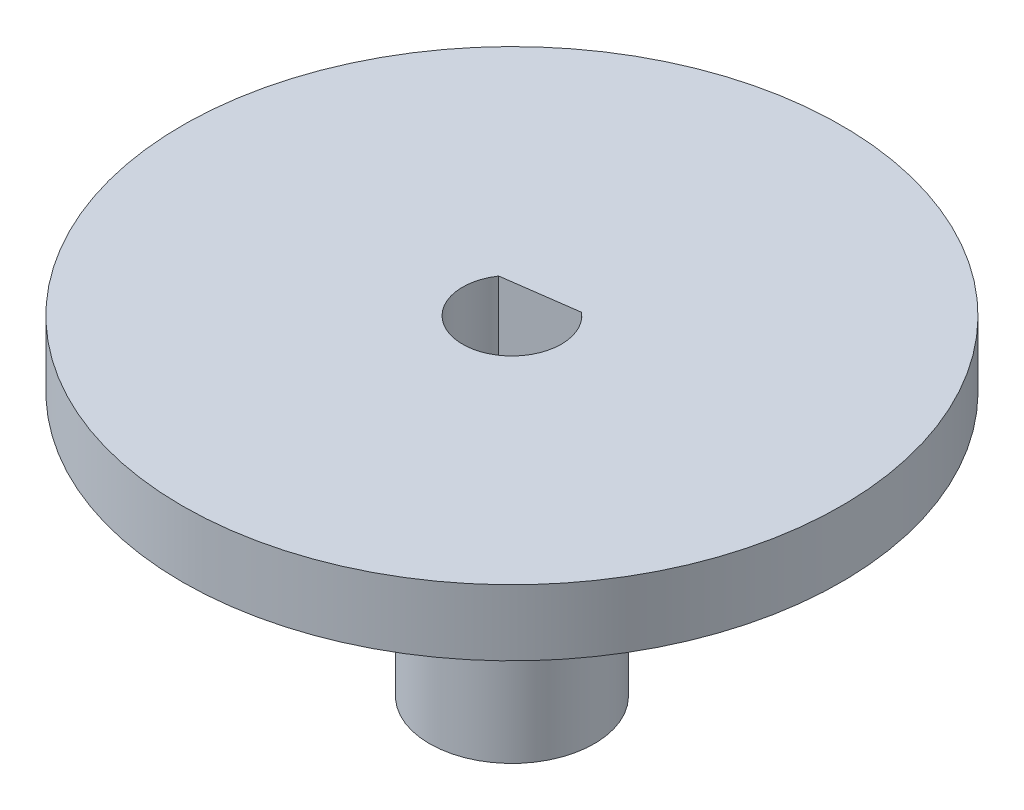
from build123d import *

# Parameters (mm, degrees)
SKETCH1_R           = 2.5
BOSS_EXTRUDE1_DEPTH = 10
SKETCH3_R           = 10
SKETCH3_R_2         = 2.5
BOSS_EXTRUDE2_DEPTH = 2


with BuildPart() as part:
    # Sketch1 → Boss-Extrude1 (new body)
    with BuildSketch(Plane(origin=(0, 0, 0), x_dir=(1, 0, 0), z_dir=(0, 1, 0))):
        Circle(SKETCH1_R)
        with BuildLine():
            Line((-1.242447099, 0.840431559), (0.968768208, 1.14513458))
            ThreePointArc((0.968768208, 1.14513458), (0.204756352, -1.485907091), (-1.242447099, 0.840431559))
        make_face(mode=Mode.SUBTRACT)
    extrude(amount=BOSS_EXTRUDE1_DEPTH)

    # Sketch3 → Boss-Extrude2 (add)
    with BuildSketch(Plane(origin=(0, 10, 0), x_dir=(1, 0, 0), z_dir=(0, 1, 0))):
        Circle(SKETCH3_R)
        Circle(SKETCH3_R_2, mode=Mode.SUBTRACT)
    extrude(amount=-BOSS_EXTRUDE2_DEPTH)


solid = part.part
